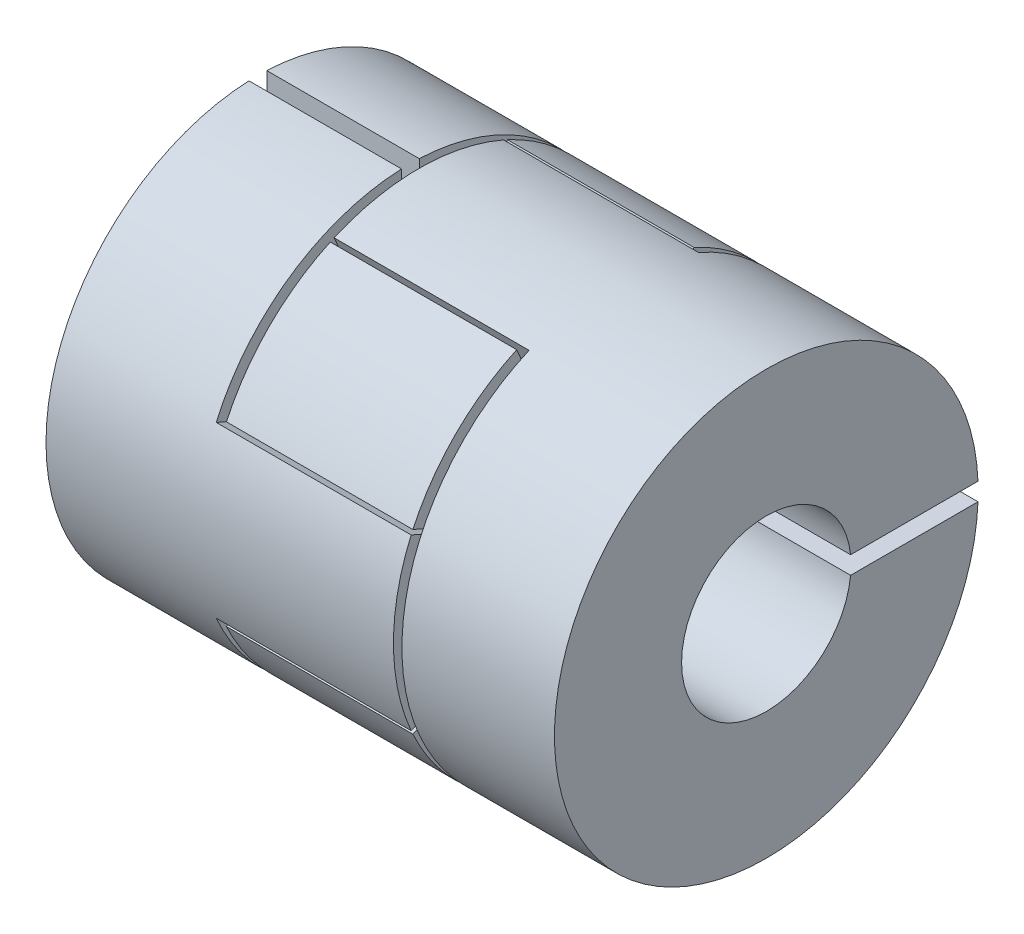
from build123d import *

# Parameters (mm, degrees)
SKETCH1_R           = 12.5
SKETCH1_R_2         = 5
BOSS_EXTRUDE1_DEPTH = 9
BOSS_EXTRUDE3_DEPTH = 11.5
CUT_EXTRUDE1_DEPTH  = 28.069355367
SKETCH5_R           = 12.5
SKETCH5_R_2         = 3.175
BOSS_EXTRUDE5_DEPTH = 9
CUT_EXTRUDE2_START  = -9
CUT_EXTRUDE2_DEPTH  = 9
BOSS_EXTRUDE6_START = 11.5
BOSS_EXTRUDE6_DEPTH = 11.5
BOSS_EXTRUDE7_DEPTH = 11


with BuildPart() as part:
    # Sketch1 → Boss-Extrude1 (new body)
    with BuildSketch(Plane(origin=(15, 0, 0), x_dir=(0, 0, -1), z_dir=(1, 0, 0))):
        Circle(SKETCH1_R)
        Circle(SKETCH1_R_2, mode=Mode.SUBTRACT)
    extrude(amount=-BOSS_EXTRUDE1_DEPTH)

    # Sketch3 → Boss-Extrude3 (add)
    with BuildSketch(Plane.ZY.offset(-6)):
        with BuildLine():
            Line((2.4, 5.499090834), (5, 11.456439237))
            ThreePointArc((5, 11.456439237), (0, 12.5), (-5, 11.456439237))
            Line((-5, 11.456439237), (-2.4, 5.499090834))
            ThreePointArc((-2.4, 5.499090834), (0, 6), (2.4, 5.499090834))
        make_face()
        with BuildLine():
            Line((2.4, -5.499090834), (5, -11.456439237))
            ThreePointArc((5, -11.456439237), (0, -12.5), (-5, -11.456439237))
            Line((-5, -11.456439237), (-2.4, -5.499090834))
            ThreePointArc((-2.4, -5.499090834), (0, -6), (2.4, -5.499090834))
        make_face()
    extrude(amount=BOSS_EXTRUDE3_DEPTH)

    # Sketch4 → Cut-Extrude1 (cut, through all)
    with BuildSketch(Plane(origin=(15, 0, 0), x_dir=(0, 0, -1), z_dir=(1, 0, 0))):
        with BuildLine():
            Line((4.972361109, -0.525), (12.488970134, -0.525))
            ThreePointArc((12.488970134, -0.525), (12.5, 0), (12.488970134, 0.525))
            Line((12.488970134, 0.525), (4.972361109, 0.525))
            ThreePointArc((4.972361109, 0.525), (5, 0), (4.972361109, -0.525))
        make_face()
    extrude(amount=-CUT_EXTRUDE1_DEPTH, mode=Mode.SUBTRACT)


with BuildPart() as body_2:
    # Sketch5 → Boss-Extrude5 (new body)
    with BuildSketch(Plane(origin=(-15, 0, 0), x_dir=(0, 0, -1), z_dir=(1, 0, 0))):
        Circle(SKETCH5_R)
        Circle(SKETCH5_R_2, mode=Mode.SUBTRACT)
    extrude(amount=BOSS_EXTRUDE5_DEPTH)

    # Sketch6 → Cut-Extrude2 (cut)
    with BuildSketch(Plane.ZY.offset(15).offset(CUT_EXTRUDE2_START)):
        with BuildLine():
            Line((0.525, 3.131293662), (0.525, 12.488970134))
            ThreePointArc((0.525, 12.488970134), (0, 12.5), (-0.525, 12.488970134))
            Line((-0.525, 12.488970134), (-0.525, 3.131293662))
            ThreePointArc((-0.525, 3.131293662), (0, 3.175), (0.525, 3.131293662))
        make_face()
    extrude(amount=CUT_EXTRUDE2_DEPTH, mode=Mode.SUBTRACT)

    # Sketch7 → Boss-Extrude6 (add)
    with BuildSketch(Plane(origin=(-6, 0, 0), x_dir=(0, 0, -1), z_dir=(1, 0, 0)).offset(BOSS_EXTRUDE6_START)):
        with BuildLine():
            Line((5.499090834, 2.4), (11.456439237, 5))
            ThreePointArc((11.456439237, 5), (12.5, 0), (11.456439237, -5))
            Line((11.456439237, -5), (5.499090834, -2.4))
            ThreePointArc((5.499090834, -2.4), (6, 0), (5.499090834, 2.4))
        make_face()
        with BuildLine():
            Line((-5.499090834, 2.4), (-11.456439237, 5))
            ThreePointArc((-11.456439237, 5), (-12.5, 0), (-11.456439237, -5))
            Line((-11.456439237, -5), (-5.499090834, -2.4))
            ThreePointArc((-5.499090834, -2.4), (-6, 0), (-5.499090834, 2.4))
        make_face()
    extrude(amount=-BOSS_EXTRUDE6_DEPTH)


with BuildPart() as body_3:
    # Sketch8 → Boss-Extrude7 (new body)
    with BuildSketch(Plane.ZY.offset(5.5)):
        with BuildLine():
            Line((5.228128685, -11.35414772), (2.526953843, -5.164978632))
            ThreePointArc((2.526953843, -5.164978632), (0, -5.75), (-2.526953843, -5.164978632))
            Line((-2.526953843, -5.164978632), (-5.228128685, -11.35414772))
            ThreePointArc((-5.228128685, -11.35414772), (-8.838834765, -8.838834765), (-11.35414772, -5.228128685))
            Line((-11.35414772, -5.228128685), (-5.164978632, -2.526953843))
            ThreePointArc((-5.164978632, -2.526953843), (-5.75, 0), (-5.164978632, 2.526953843))
            Line((-5.164978632, 2.526953843), (-11.35414772, 5.228128685))
            ThreePointArc((-11.35414772, 5.228128685), (-8.838834765, 8.838834765), (-5.228128685, 11.35414772))
            Line((-5.228128685, 11.35414772), (-2.526953843, 5.164978632))
            ThreePointArc((-2.526953843, 5.164978632), (0, 5.75), (2.526953843, 5.164978632))
            Line((2.526953843, 5.164978632), (5.228128685, 11.35414772))
            ThreePointArc((5.228128685, 11.35414772), (8.838834765, 8.838834765), (11.35414772, 5.228128685))
            Line((11.35414772, 5.228128685), (5.164978632, 2.526953843))
            ThreePointArc((5.164978632, 2.526953843), (5.75, 0), (5.164978632, -2.526953843))
            Line((5.164978632, -2.526953843), (11.35414772, -5.228128685))
            ThreePointArc((11.35414772, -5.228128685), (8.838834765, -8.838834765), (5.228128685, -11.35414772))
        make_face()
    extrude(amount=-BOSS_EXTRUDE7_DEPTH)


solid = Compound([part.part, body_2.part, body_3.part])
